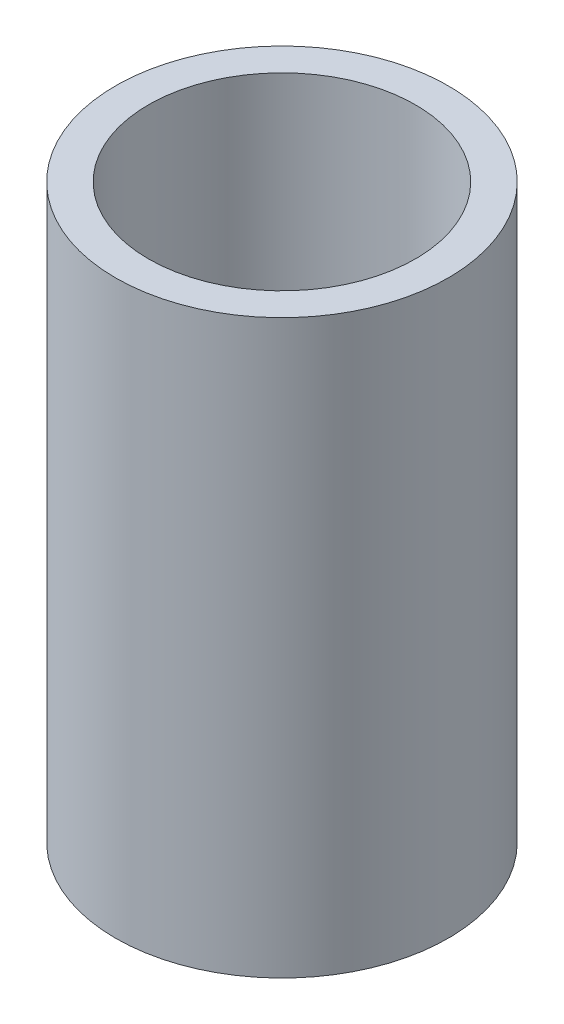
from build123d import *

# Parameters (mm, degrees)
SKETCH1_R           = 16
SKETCH1_R_2         = 12.8397
BOSS_EXTRUDE1_DEPTH = 27.5
CUT_EXTRUDE1_REACH  = 18
SKETCH2_R           = 2


with BuildPart() as part:
    # Sketch1 → Boss-Extrude1 (new body, symmetric)
    with BuildSketch(Plane(origin=(0, 0, 0), x_dir=(1, 0, 0), z_dir=(0, 1, 0))):
        Circle(SKETCH1_R)
        Circle(SKETCH1_R_2, mode=Mode.SUBTRACT)
    extrude(amount=BOSS_EXTRUDE1_DEPTH, both=True)

    # Sketch2 → Cut-Extrude1 (cut, up to next)
    with BuildSketch(Plane.XY, mode=Mode.PRIVATE) as cut_extrude1_sk1:
        Circle(SKETCH2_R)
    cut_extrude1_tool1 = extrude(cut_extrude1_sk1.sketch, amount=-CUT_EXTRUDE1_REACH, mode=Mode.PRIVATE) & part.part
    add(cut_extrude1_tool1.solids().sort_by_distance((0, 0, 0))[0], mode=Mode.SUBTRACT)


solid = part.part
